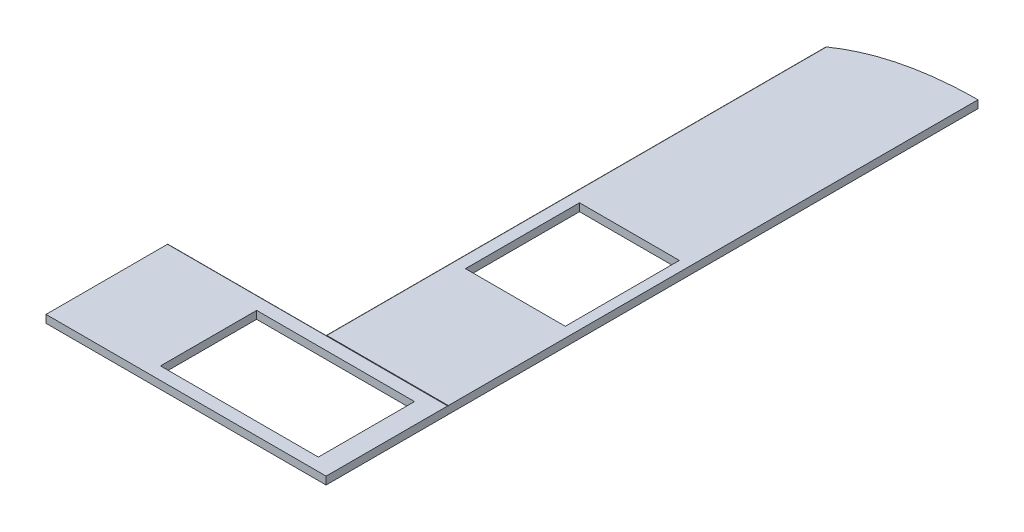
from build123d import *

# Parameters (mm, degrees)
BOSS_EXTRUDE1_DEPTH = 1375
BOSS_EXTRUDE2_DEPTH = 2600
SKETCH4_W           = 775
SKETCH4_H           = 472
SINK_DEPTH          = 39
SKETCH5_W           = 490
SKETCH5_H           = 560
PANEL_DEPTH         = 39
CUT_EXTRUDE2_DEPTH  = 39


with BuildPart() as part:
    # Sketch2 → Boss-Extrude1 (new body)
    with BuildSketch(Plane(origin=(0, 0, 0), x_dir=(0, 0, -1), z_dir=(1, 0, 0))):
        with BuildLine():
            Line((296, -19), (-300, -19))
            Line((-300, -19), (-300, 19))
            Line((-300, 19), (296, 19))
            ThreePointArc((296, 19), (298.828427125, 17.828427125), (300, 15))
            Line((300, 15), (300, -15))
            ThreePointArc((300, -15), (298.828427125, -17.828427125), (296, -19))
        make_face()
    extrude(amount=BOSS_EXTRUDE1_DEPTH)

    # Sketch3 → Boss-Extrude2 (add)
    with BuildSketch(Plane(origin=(0, 0, -300), x_dir=(-1, 0, 0), z_dir=(0, 0, -1))):
        with BuildLine():
            Line((-1375, 19), (-779, 19))
            ThreePointArc((-779, 19), (-776.171572875, 17.828427125), (-775, 15))
            Line((-775, 15), (-775, -15))
            ThreePointArc((-775, -15), (-776.171572875, -17.828427125), (-779, -19))
            Line((-779, -19), (-1375, -19))
            Line((-1375, -19), (-1375, 19))
        make_face()
    extrude(amount=BOSS_EXTRUDE2_DEPTH)

    # Sketch4 → sink (cut, through all)
    with BuildSketch(Plane(origin=(0, 19, 0), x_dir=(1, 0, 0), z_dir=(0, 1, 0))):
        with Locations((887.5, -2)):
            Rectangle(SKETCH4_W, SKETCH4_H)
    extrude(amount=-SINK_DEPTH, mode=Mode.SUBTRACT)

    # Sketch5 → panel (cut, through all)
    with BuildSketch(Plane(origin=(0, 19, 0), x_dir=(1, 0, 0), z_dir=(0, 1, 0))):
        with Locations((1080, 1204)):
            Rectangle(SKETCH5_W, SKETCH5_H)
    extrude(amount=-PANEL_DEPTH, mode=Mode.SUBTRACT)

    # Sketch7 → Cut-Extrude2 (cut, through all)
    with BuildSketch(Plane(origin=(0, 19, 0), x_dir=(1, 0, 0), z_dir=(0, 1, 0))):
        with BuildLine():
            Line((775, 2750), (581.090205062, 2808.629512904))
            Line((581.090205062, 2808.629512904), (669.529135366, 3022.428480339))
            Line((669.529135366, 3022.428480339), (1128.037764323, 3045.611500904))
            Line((1128.037764323, 3045.611500904), (1325.322294603, 3055.586561424))
            Line((1325.322294603, 3055.586561424), (1375, 2900))
            add(Edge.make_bspline(
                [(775, 2750), (983.393090417, 2898.416607851), (1375, 2900)],
                knots=[0, 0, 0, 1, 1, 1], degree=2))
        make_face()
    extrude(amount=-CUT_EXTRUDE2_DEPTH, mode=Mode.SUBTRACT)


solid = part.part
